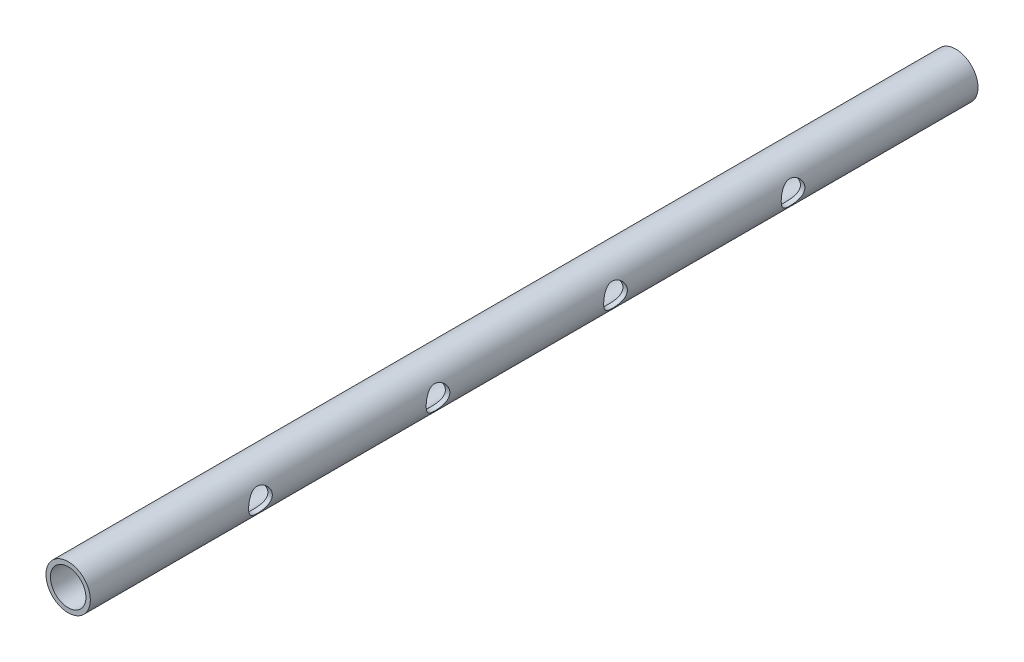
from build123d import *

# Parameters (mm, degrees)
SKETCH1_R           = 7.5
SKETCH1_R_2         = 6
BOSS_EXTRUDE1_DEPTH = 300
SKETCH2_R           = 4
CUT_EXTRUDE1_DEPTH  = 6


with BuildPart() as part:
    # Sketch1 → Boss-Extrude1 (new body)
    with BuildSketch(Plane.XY):
        Circle(SKETCH1_R)
        Circle(SKETCH1_R_2, mode=Mode.SUBTRACT)
    extrude(amount=BOSS_EXTRUDE1_DEPTH)

    # Sketch2 → Cut-Extrude1 (cut)
    with BuildSketch(Plane(origin=(7.5, 0, 0), x_dir=(0, 0, -1), z_dir=(1, 0, 0))):
        with Locations((-242.5, 0)):
            Circle(SKETCH2_R)
        with Locations((-182.5, 0)):
            Circle(SKETCH2_R)
        with Locations((-122.5, 0)):
            Circle(SKETCH2_R)
        with Locations((-62.5, 0)):
            Circle(SKETCH2_R)
    extrude(amount=-CUT_EXTRUDE1_DEPTH, mode=Mode.SUBTRACT)


solid = part.part
